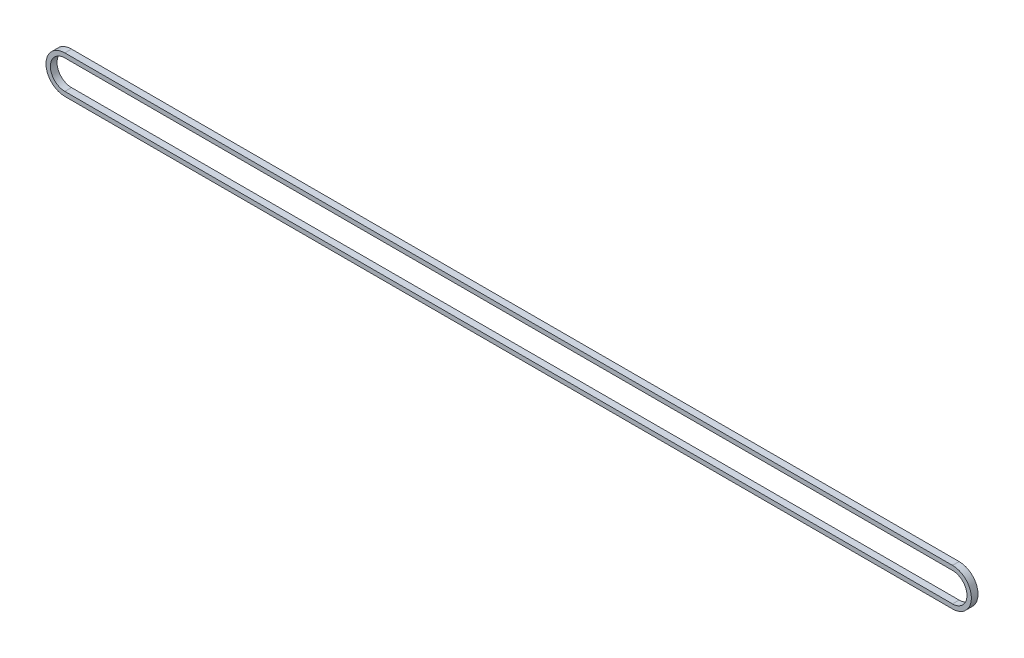
from build123d import *

# Parameters (mm, degrees)
EXTRUDE_THIN1_DEPTH = 4.445


with BuildPart() as part:
    # Sketch1 → Extrude-Thin1 (new body, symmetric)
    with BuildSketch(Plane.XY):
        with BuildLine():
            Line((1187.45, -25.230690532), (0, -25.230690532))
            ThreePointArc((0, -25.230690532), (-25.230690532, 0), (0, 25.230690532))
            Line((0, 25.230690532), (1187.45, 25.230690532))
            ThreePointArc((1187.45, 25.230690532), (1212.680690532, 0), (1187.45, -25.230690532))
        make_face()
        with BuildLine():
            Line((1187.45, -19.388690532), (0, -19.388690532))
            ThreePointArc((0, -19.388690532), (-19.388690532, 0), (0, 19.388690532))
            Line((0, 19.388690532), (1187.45, 19.388690532))
            ThreePointArc((1187.45, 19.388690532), (1206.838690532, 0), (1187.45, -19.388690532))
        make_face(mode=Mode.SUBTRACT)
    extrude(amount=EXTRUDE_THIN1_DEPTH, both=True)


solid = part.part
